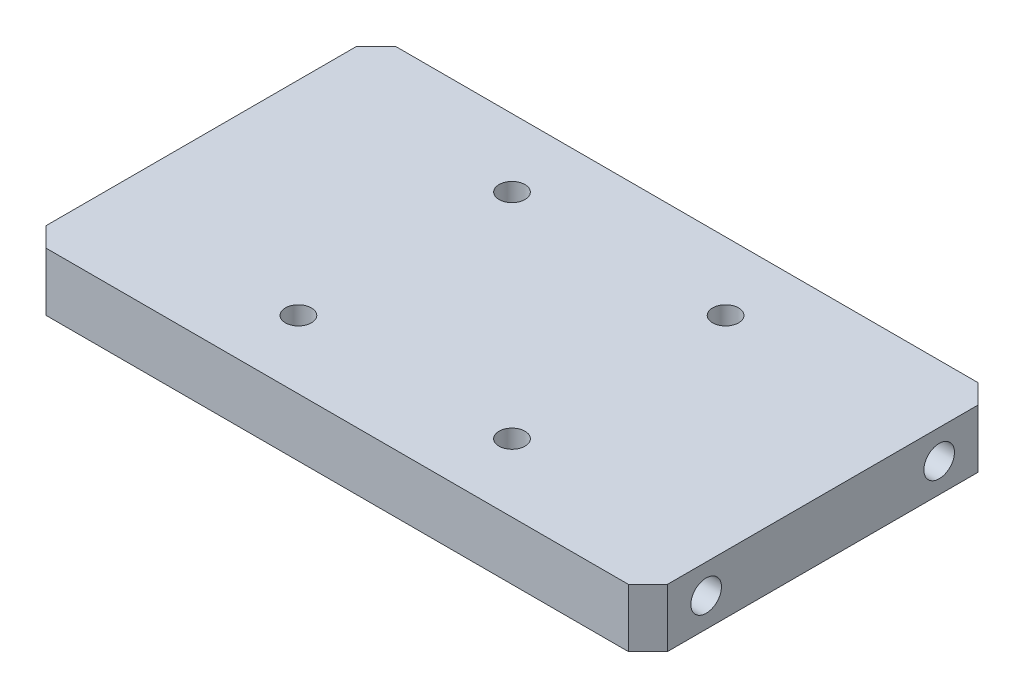
from build123d import *

# Parameters (mm, degrees)
SKETCH1_W              = 203.2
SKETCH1_H              = 114.3
BOSS_EXTRUDE1_DEPTH    = 19.05
SKETCH2_R              = 5
CUT_EXTRUDE1_DEPTH     = 19.05
CHAMFER1_SIZE          = 6.35
M10X1_5_TAPPED_HOLE1_D = 8.5


with BuildPart() as part:
    # Sketch1 → Boss-Extrude1 (new body)
    with BuildSketch(Plane(origin=(0, 0, 0), x_dir=(1, 0, 0), z_dir=(0, 1, 0))):
        Rectangle(SKETCH1_W, SKETCH1_H)
    extrude(amount=BOSS_EXTRUDE1_DEPTH)

    # Sketch2 → Cut-Extrude1 (cut)
    with BuildSketch(Plane.ZY.offset(101.6)):
        with Locations((-38.1, 9.525)):
            Circle(SKETCH2_R)
        with Locations((38.1, 9.525)):
            Circle(SKETCH2_R)
    cut_extrude1 = extrude(amount=-CUT_EXTRUDE1_DEPTH, mode=Mode.SUBTRACT)

    # Mirror1: Cut-Extrude1 across plane
    add(cut_extrude1.mirror(Plane(origin=(0, 0, 0), x_dir=(0, 0, 1), z_dir=(1, 0, 0))), mode=Mode.SUBTRACT)

    # Chamfer1
    chamfer1_edges = [part.edges().sort_by_distance(p)[0] for p in [
        (101.6, 9.525, 57.15),
        (-101.6, 9.525, 57.15),
        (-101.6, 9.525, -57.15),
        (101.6, 9.525, -57.15),
    ]]
    chamfer(chamfer1_edges, length=CHAMFER1_SIZE)

    # M10x1.5 Tapped Hole1 (through all)
    with Locations(Plane(origin=(0, 19.05, 0), x_dir=(1, 0, 0), z_dir=(0, 1, 0))):
        with Locations((34.925, -34.925), (-34.925, -34.925), (34.925, 34.925), (-34.925, 34.925)):
            Hole(M10X1_5_TAPPED_HOLE1_D / 2)


solid = part.part
